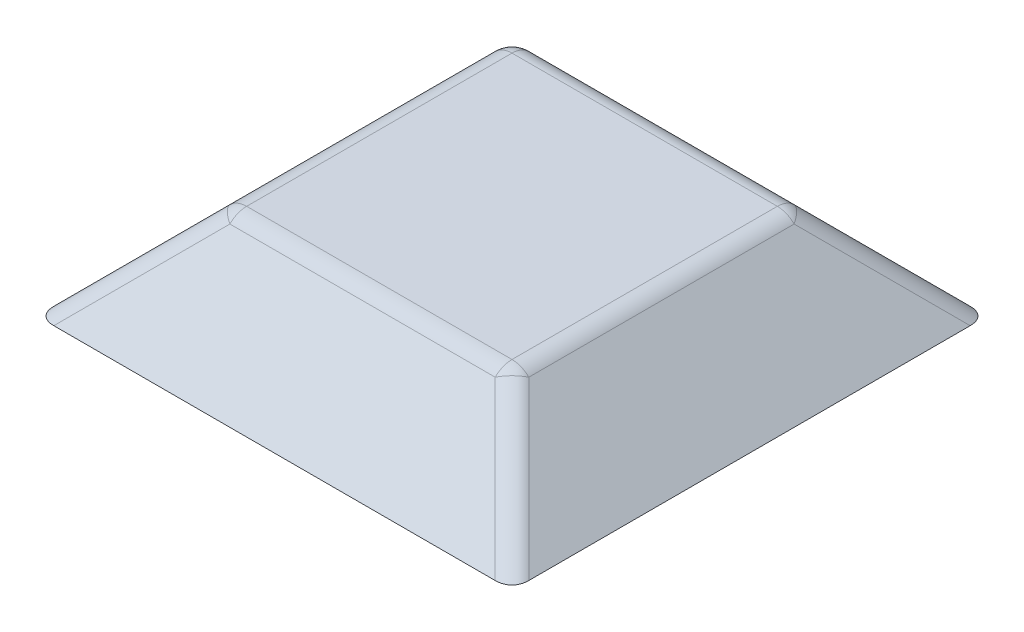
from build123d import *

# Parameters (mm, degrees)
CROQUIS1_W              = 10
CROQUIS1_H              = 10
SALIENTE_EXTRUIR1_DEPTH = 2
SALIENTE_EXTRUIR1_TAPER = 45
REDONDEO1_R             = 0.5


with BuildPart() as part:
    # Croquis1 → Saliente-Extruir1 (new body)
    with BuildSketch(Plane(origin=(0, 0, 0), x_dir=(1, 0, 0), z_dir=(0, 1, 0))):
        Rectangle(CROQUIS1_W, CROQUIS1_H)
    extrude(amount=SALIENTE_EXTRUIR1_DEPTH, taper=SALIENTE_EXTRUIR1_TAPER)

    # Redondeo1
    redondeo1_edges = [part.edges().sort_by_distance(p)[0] for p in [
        (3, 2, 0),
        (0, 2, -3),
        (-3, 2, 0),
        (0, 2, 3),
        (-4, 1, -4),
        (4, 1, -4),
        (4, 1, 4),
        (-4, 1, 4),
    ]]
    fillet(redondeo1_edges, radius=REDONDEO1_R)


solid = part.part
